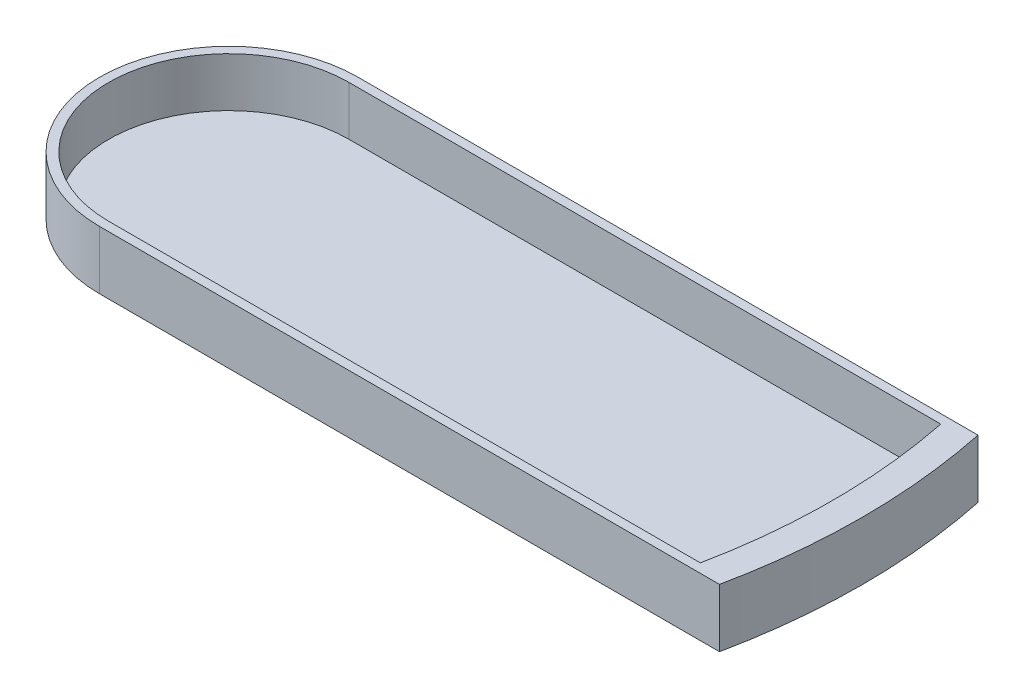
from build123d import *

# Parameters (mm, degrees)
BOSS_EXTRUDE2_DEPTH = 2
BOSS_EXTRUDE3_START = 10.9
BOSS_EXTRUDE3_DEPTH = 10.9


with BuildPart() as part:
    # Sketch1 → Boss-Extrude2 (new body)
    with BuildSketch(Plane(origin=(0, 0, 0), x_dir=(1, 0, 0), z_dir=(0, 1, 0))):
        with BuildLine():
            Line((0, 28.575), (137.052797764, 28.575))
            ThreePointArc((137.052797764, 28.575), (139.26125033, 14.36329198), (140, 0))
            ThreePointArc((140, 0), (139.26125033, -14.36329198), (137.052797764, -28.575))
            Line((137.052797764, -28.575), (0, -28.575))
            ThreePointArc((0, -28.575), (-28.575, 0), (0, 28.575))
        make_face()
    extrude(amount=-BOSS_EXTRUDE2_DEPTH)

    # Sketch1_14 → Boss-Extrude3 (add)
    with BuildSketch(Plane(origin=(0, 0, 0), x_dir=(1, 0, 0), z_dir=(0, 1, 0)).offset(BOSS_EXTRUDE3_START)):
        with BuildLine():
            Line((0, 28.575), (137.052797764, 28.575))
            ThreePointArc((137.052797764, 28.575), (139.26125033, 14.36329198), (140, 0))
            ThreePointArc((140, 0), (139.26125033, -14.36329198), (137.052797764, -28.575))
            Line((137.052797764, -28.575), (0, -28.575))
            ThreePointArc((0, -28.575), (-28.575, 0), (0, 28.575))
        make_face()
        with BuildLine():
            Line((0, -26.575), (130.828205579, -26.575))
            ThreePointArc((130.828205579, -26.575), (132.830371988, -13.354485299), (133.5, 0))
            ThreePointArc((133.5, 0), (132.830371988, 13.354485299), (130.828205579, 26.575))
            Line((130.828205579, 26.575), (0, 26.575))
            ThreePointArc((0, 26.575), (-26.575, 0), (0, -26.575))
        make_face(mode=Mode.SUBTRACT)
    extrude(amount=-BOSS_EXTRUDE3_DEPTH)


solid = part.part
